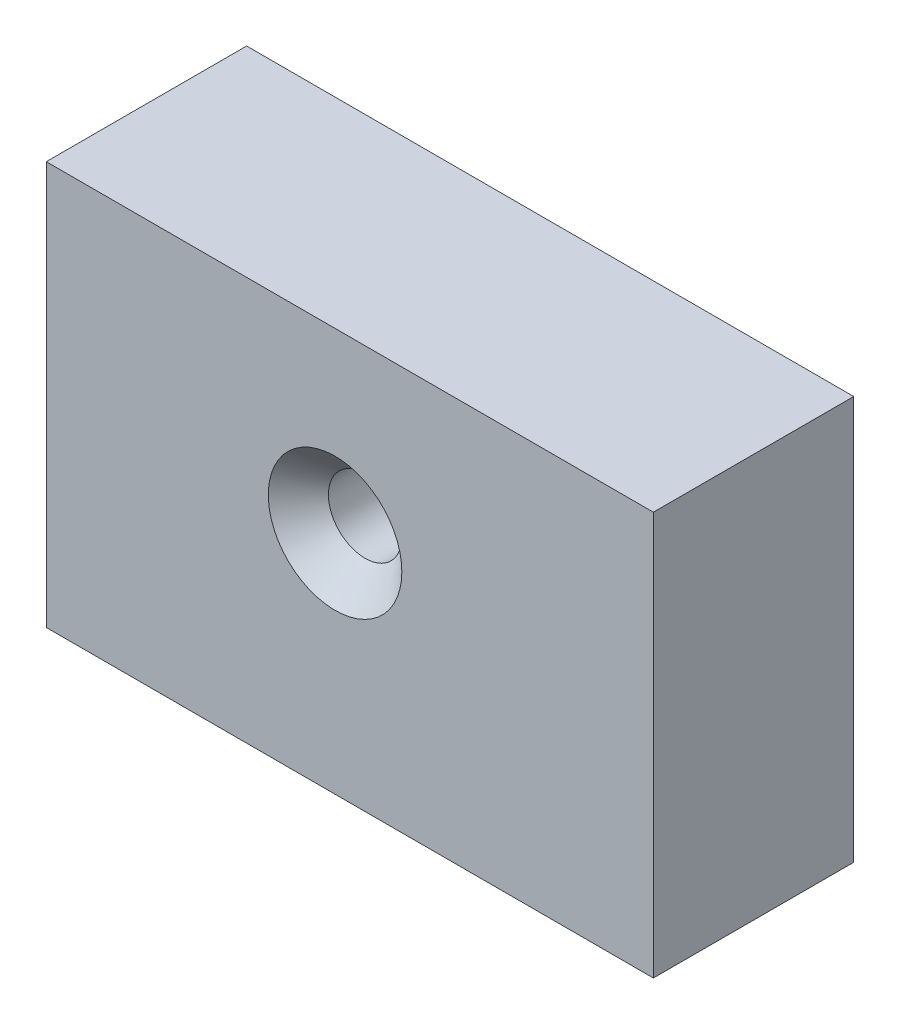
from build123d import *

# Parameters (mm, degrees)
SKETCH1_W                                            = 90.903302848
SKETCH1_H                                            = 60.405441503
BOSS_EXTRUDE1_DEPTH                                  = 30
CSK_FOR_M10_COUNTERSUNK_FLAT_HEAD_SCREW1_D           = 11
CSK_FOR_M10_COUNTERSUNK_FLAT_HEAD_SCREW1_DEPTH       = 25
CSK_FOR_M10_COUNTERSUNK_FLAT_HEAD_SCREW1_CSINK_D     = 20
CSK_FOR_M10_COUNTERSUNK_FLAT_HEAD_SCREW1_CSINK_ANGLE = 90
CSK_FOR_M10_COUNTERSUNK_FLAT_HEAD_SCREW1_TIP         = 3.304733405


with BuildPart() as part:
    # Sketch1 → Boss-Extrude1 (new body)
    with BuildSketch(Plane.XY):
        with Locations((16.331112849, -3.640067322)):
            Rectangle(SKETCH1_W, SKETCH1_H)
    extrude(amount=BOSS_EXTRUDE1_DEPTH)

    # CSK for M10 Countersunk Flat Head Screw1
    with Locations(Plane.XY.offset(30)):
        with Locations((14.120214228, 0)):
            CounterSinkHole(CSK_FOR_M10_COUNTERSUNK_FLAT_HEAD_SCREW1_D / 2, CSK_FOR_M10_COUNTERSUNK_FLAT_HEAD_SCREW1_CSINK_D / 2, depth=CSK_FOR_M10_COUNTERSUNK_FLAT_HEAD_SCREW1_DEPTH, counter_sink_angle=CSK_FOR_M10_COUNTERSUNK_FLAT_HEAD_SCREW1_CSINK_ANGLE)
            with Locations((0, 0, -(CSK_FOR_M10_COUNTERSUNK_FLAT_HEAD_SCREW1_DEPTH + CSK_FOR_M10_COUNTERSUNK_FLAT_HEAD_SCREW1_TIP / 2))):  # 118° drill point
                Cone(0, CSK_FOR_M10_COUNTERSUNK_FLAT_HEAD_SCREW1_D / 2, CSK_FOR_M10_COUNTERSUNK_FLAT_HEAD_SCREW1_TIP, mode=Mode.SUBTRACT)


solid = part.part
